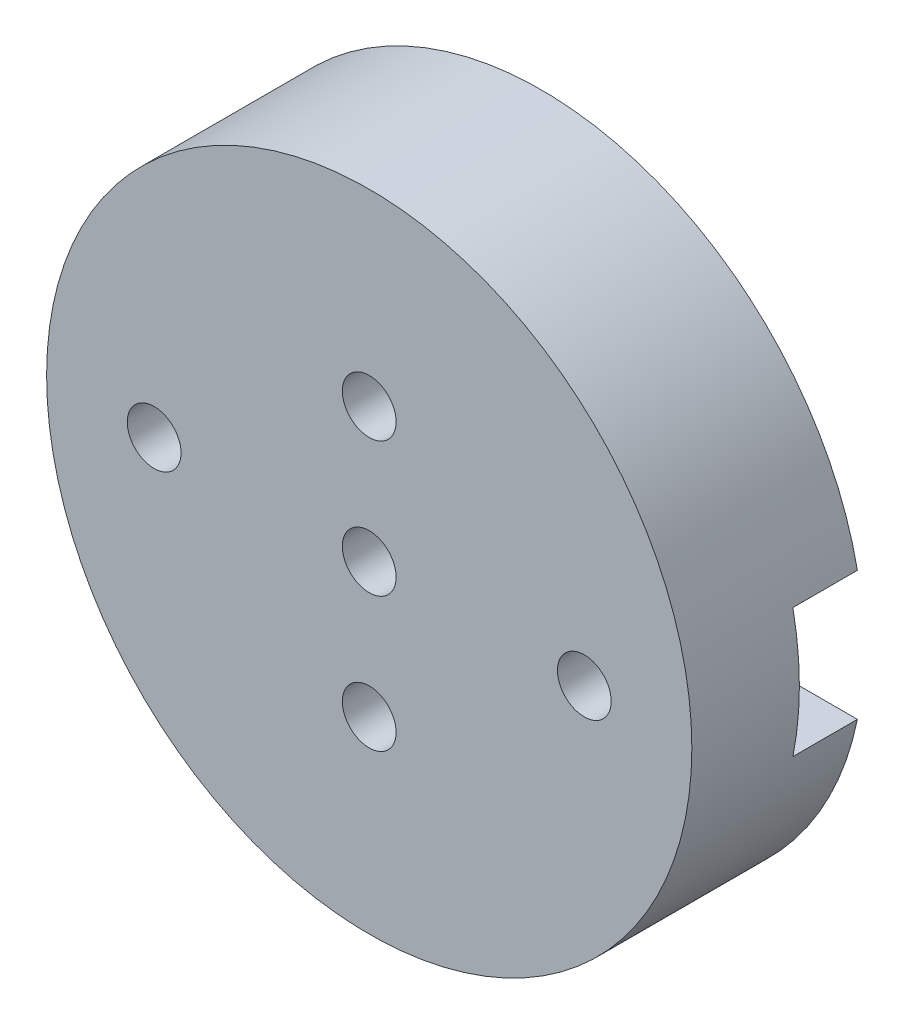
from build123d import *

# Parameters (mm, degrees)
SKETCH2_R           = 60
SKETCH2_R_2         = 5
BOSS_EXTRUDE1_DEPTH = 32
SKETCH4_R           = 5
CUT_EXTRUDE2_DEPTH  = 12
CUT_EXTRUDE3_DEPTH  = 12


with BuildPart() as part:
    # Sketch2 → Boss-Extrude1 (new body)
    with BuildSketch(Plane.XY):
        Circle(SKETCH2_R)
        Circle(SKETCH2_R_2, mode=Mode.SUBTRACT)
        with Locations((40, 0)):
            Circle(SKETCH2_R_2, mode=Mode.SUBTRACT)
        with Locations((-40, 0)):
            Circle(SKETCH2_R_2, mode=Mode.SUBTRACT)
        with Locations((0, 25)):
            Circle(SKETCH2_R_2, mode=Mode.SUBTRACT)
        with Locations((0, -25)):
            Circle(SKETCH2_R_2, mode=Mode.SUBTRACT)
    extrude(amount=BOSS_EXTRUDE1_DEPTH)

    # Sketch4 → Cut-Extrude2 (cut)
    with BuildSketch(Plane.XY):
        with BuildLine():
            Line((12, 12), (12, 25))
            ThreePointArc((12, 25), (0, 37), (-12, 25))
            Line((-12, 25), (-12, 12))
            Line((-12, 12), (-58.787753827, 12))
            ThreePointArc((-58.787753827, 12), (-60, 0), (-58.787753827, -12))
            Line((-58.787753827, -12), (-12, -12))
            Line((-12, -12), (-12, -25))
            ThreePointArc((-12, -25), (0, -37), (12, -25))
            Line((12, -25), (12, -12))
            Line((12, -12), (58.787753827, -12))
            ThreePointArc((58.787753827, -12), (59.69616918, -6.03053772), (60, 0))
            ThreePointArc((60, 0), (59.69616918, 6.03053772), (58.787753827, 12))
            Line((58.787753827, 12), (12, 12))
        make_face()
        with Locations((-40, 0)):
            Circle(SKETCH4_R, mode=Mode.SUBTRACT)
        with Locations((0, -25)):
            Circle(SKETCH4_R, mode=Mode.SUBTRACT)
        Circle(SKETCH4_R, mode=Mode.SUBTRACT)
        with Locations((40, 0)):
            Circle(SKETCH4_R, mode=Mode.SUBTRACT)
        with Locations((0, 25)):
            Circle(SKETCH4_R, mode=Mode.SUBTRACT)
    extrude(amount=CUT_EXTRUDE2_DEPTH, mode=Mode.SUBTRACT)

    # Sketch5 → Cut-Extrude3 (cut)
    with BuildSketch(Plane.XY):
        with BuildLine():
            ThreePointArc((27.613309165, 47.565798185), (0.130928127, 54.999844162), (-27.386534997, 47.696726312))
            ThreePointArc((-27.386534997, 47.696726312), (-29.602192231, 39.505825078), (-21.411290998, 37.290167844))
            ThreePointArc((-21.411290998, 37.290167844), (0.10236199, 42.999878163), (21.588587165, 37.187805854))
            ThreePointArc((21.588587165, 37.187805854), (29.789944331, 39.364441019), (27.613309165, 47.565798185))
        make_face()
        with BuildLine():
            ThreePointArc((-27.464289902, -47.832145212), (-29.679947137, -39.641243979), (-21.489045903, -37.425586744))
            ThreePointArc((-21.489045903, -37.425586744), (0.102733717, -43.156031824), (21.66698592, -37.322853027))
            ThreePointArc((21.66698592, -37.322853027), (29.868343086, -39.499488193), (27.69170792, -47.700845359))
            ThreePointArc((27.69170792, -47.700845359), (0.131299854, -55.155997823), (-27.464289902, -47.832145212))
        make_face()
    extrude(amount=CUT_EXTRUDE3_DEPTH, mode=Mode.SUBTRACT)


solid = part.part
